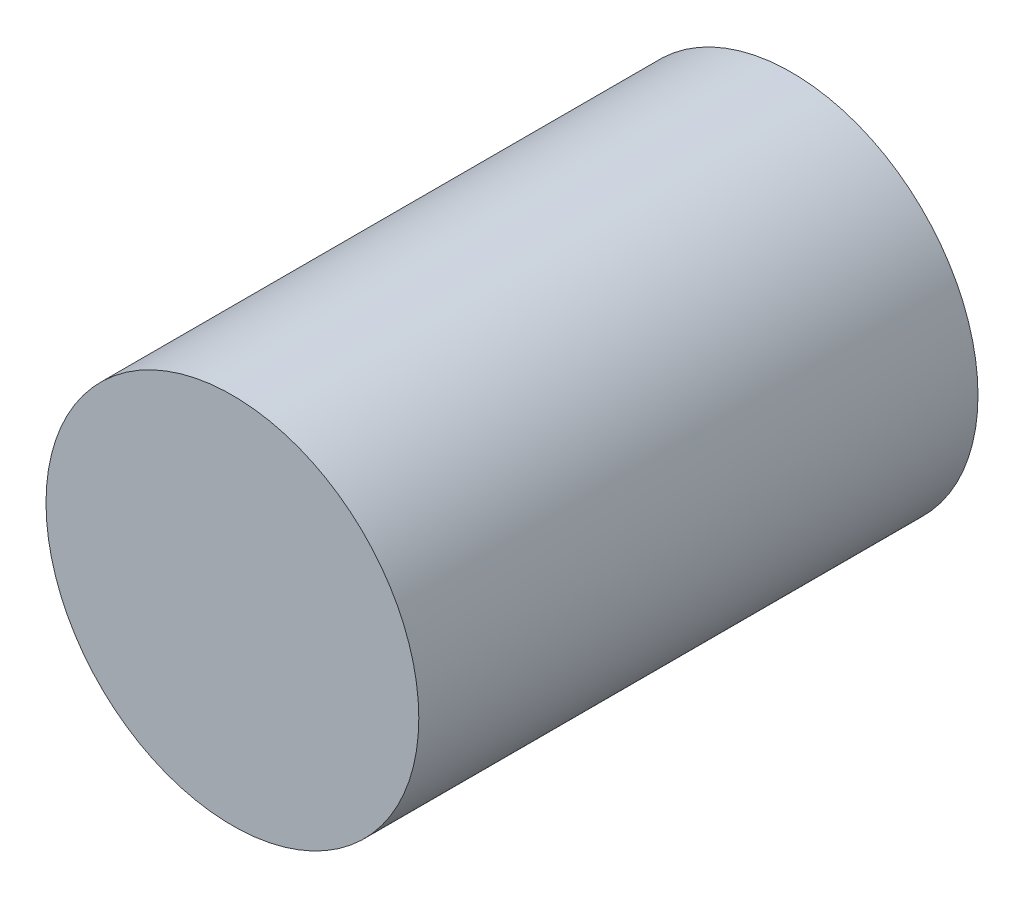
from build123d import *

# Parameters (mm, degrees)
SKETCH1_R           = 5.08
BOSS_EXTRUDE1_DEPTH = 15.24


with BuildPart() as part:
    # Sketch1 → Boss-Extrude1 (new body)
    with BuildSketch(Plane.XY):
        with Locations((-9.526903158, 14.010151704)):
            Circle(SKETCH1_R)
    extrude(amount=BOSS_EXTRUDE1_DEPTH)


solid = part.part
